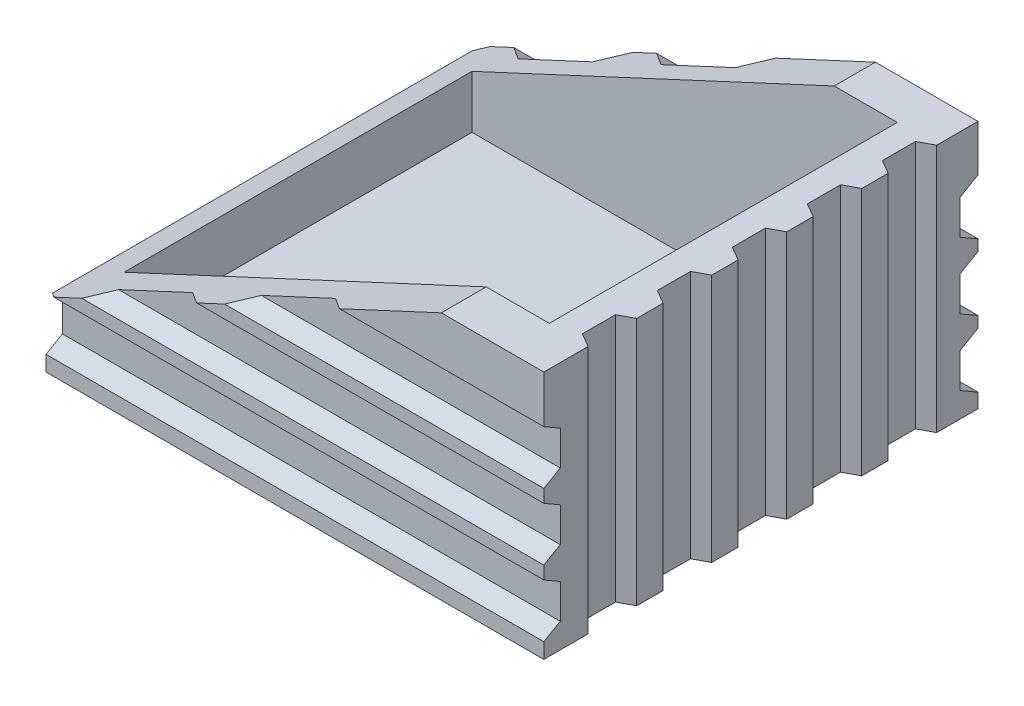
from build123d import *

# Parameters (mm, degrees)
SKETCH3_W           = 0.09
SKETCH3_H           = 0.0810914
BOSS_EXTRUDE2_DEPTH = 0.045
SKETCH4_W           = 0.076885995
SKETCH4_H           = 0.062907989
CUT_EXTRUDE2_DEPTH  = 0.04
CUT_EXTRUDE3_DEPTH  = 0.085
CUT_EXTRUDE5_DEPTH  = 0.045
CUT_EXTRUDE6_DEPTH  = 0.095
SKETCH10_W          = 0.00259893
SKETCH10_H          = 0.045
CUT_EXTRUDE7_DEPTH  = 0.095


with BuildPart() as part:
    # Sketch3 → Boss-Extrude2 (new body)
    with BuildSketch(Plane(origin=(0, 0, 0), x_dir=(1, 0, 0), z_dir=(0, 1, 0))):
        Rectangle(SKETCH3_W, SKETCH3_H)
    extrude(amount=BOSS_EXTRUDE2_DEPTH)

    # Sketch4 → Cut-Extrude2 (cut)
    with BuildSketch(Plane(origin=(0, 0.045, 0), x_dir=(1, 0, 0), z_dir=(0, 1, 0))):
        with Locations((-0.000573781, 0.00163106)):
            Rectangle(SKETCH4_W, SKETCH4_H)
    extrude(amount=-CUT_EXTRUDE2_DEPTH, mode=Mode.SUBTRACT)

    # Sketch5 → Cut-Extrude3 (cut)
    with BuildSketch(Plane(origin=(0, 0, -0.0405457), x_dir=(-1, 0, 0), z_dir=(0, 0, -1))):
        Polygon((-0.026465748, 0.045), (0.045, 0.045), (0.045, 0.011774754), align=None)
    extrude(amount=-CUT_EXTRUDE3_DEPTH, mode=Mode.SUBTRACT)

    # Sketch6 → Cut-Extrude5 (cut)
    with BuildSketch(Plane(origin=(0, 0.045, 0), x_dir=(1, 0, 0), z_dir=(0, 1, 0))):
        Polygon((0.045, 0.033085055), (0.0425, 0.031749464), (0.0425, 0.025749464), (0.045, 0.024306089), align=None)
        Polygon((0.045, 0.019525055), (0.0425, 0.018189464), (0.0425, 0.012189464), (0.045, 0.010746089), align=None)
        Polygon((0.045, 0.005965055), (0.0425, 0.004629464), (0.0425, -0.001370536), (0.045, -0.002813911), align=None)
        Polygon((0.045, -0.007594945), (0.0425, -0.008930536), (0.0425, -0.014930536), (0.045, -0.016373911), align=None)
        Polygon((0.045, -0.021154945), (0.0425, -0.022490536), (0.0425, -0.028490536), (0.045, -0.029933911), align=None)
    extrude(amount=-CUT_EXTRUDE5_DEPTH, mode=Mode.SUBTRACT)

    # Sketch8 → Cut-Extrude6 (cut)
    with BuildSketch(Plane(origin=(0.045, 0, 0), x_dir=(0, 0, -1), z_dir=(1, 0, 0))):
        Polygon((0.0405457, 0.036607841), (0.0405457, 0.02660494), (0.03727938, 0.028490751), (0.03727938, 0.034722031), align=None)
        Polygon((0.03727938, 0.022722031), (0.03727938, 0.016490751), (0.0405457, 0.01460494), (0.0405457, 0.024607841), align=None)
        Polygon((0.03727938, 0.010722031), (0.03727938, 0.004490751), (0.0405457, 0.00260494), (0.0405457, 0.012607841), align=None)
        Polygon((-0.038241693, 0.012607841), (-0.034975373, 0.010722031), (-0.034975373, 0.004490751), (-0.038241693, 0.00260494), align=None)
        Polygon((-0.038241693, 0.024607841), (-0.034975373, 0.022722031), (-0.034975373, 0.016490751), (-0.038241693, 0.01460494), align=None)
        Polygon((-0.038241693, 0.036607841), (-0.034975373, 0.034722031), (-0.034975373, 0.028490751), (-0.038241693, 0.02660494), align=None)
    extrude(amount=-CUT_EXTRUDE6_DEPTH, mode=Mode.SUBTRACT)

    # Sketch10 → Cut-Extrude7 (cut)
    with BuildSketch(Plane(origin=(0.045, 0, 0), x_dir=(0, 0, -1), z_dir=(1, 0, 0))):
        with Locations((-0.039246235, 0.0225)):
            Rectangle(SKETCH10_W, SKETCH10_H)
    extrude(amount=-CUT_EXTRUDE7_DEPTH, mode=Mode.SUBTRACT)


solid = part.part
